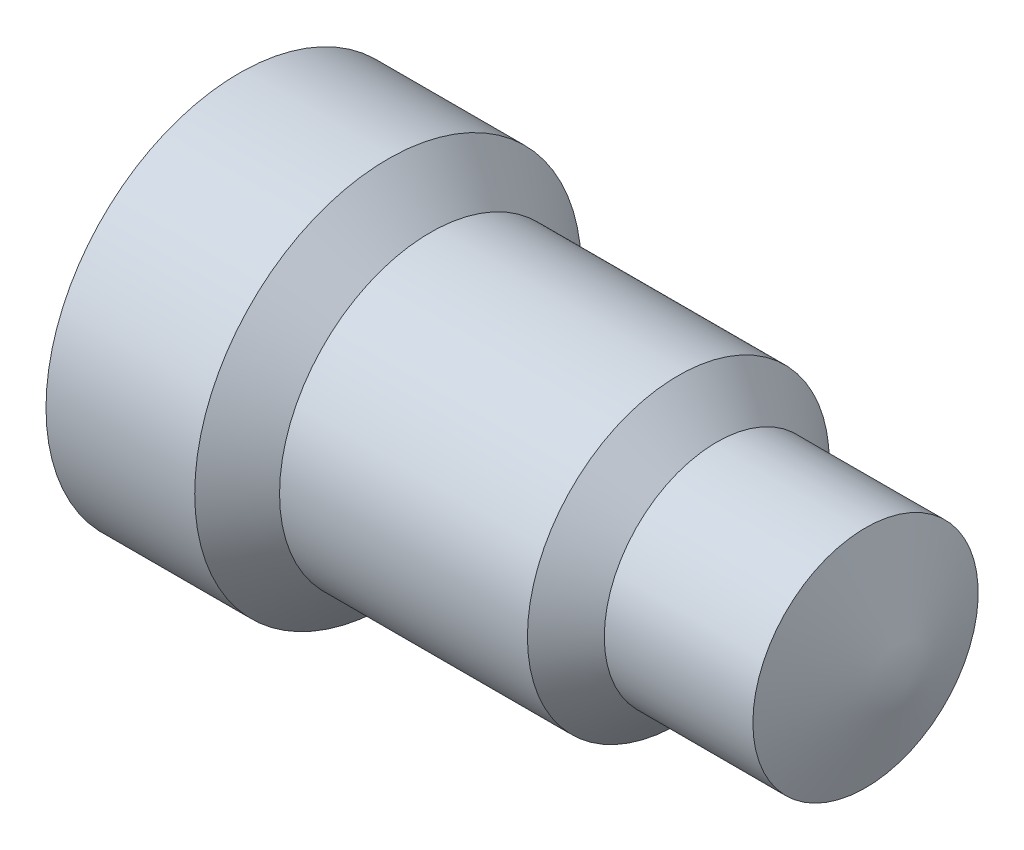
from build123d import *


with BuildPart() as part:
    # Sketch1 → Revolve2 (revolve)
    with BuildSketch(Plane.XY):
        Polygon((0, 0), (171.45, 0), (160.42219905, 28.858545587), (122.32219905, 28.828323605), (112.476215029, 38.674307625), (48.976215029, 38.674307625), (38.1, 49.53), (0, 49.53), align=None)
    revolve(axis=Axis((0, 0, 0), (1, 0, 0)))


solid = part.part
